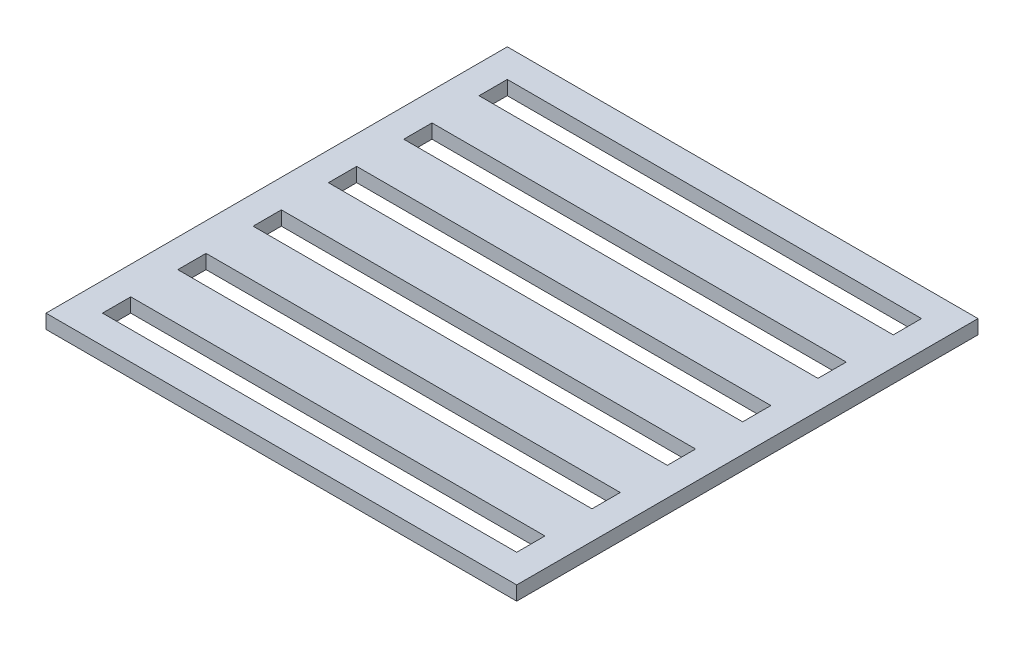
from build123d import *

# Parameters (mm, degrees)
CROQUIS3_W              = 490
CROQUIS3_H              = 15
SALIENTE_EXTRUIR1_DEPTH = 500
CROQUIS4_W              = 440
CROQUIS4_H              = 30
CORTAR_EXTRUIR1_DEPTH   = 15


with BuildPart() as part:
    # Croquis3 → Saliente-Extruir1 (new body)
    with BuildSketch(Plane(origin=(0, 0, 0), x_dir=(0, 0, -1), z_dir=(1, 0, 0))):
        Rectangle(CROQUIS3_W, CROQUIS3_H)
    extrude(amount=SALIENTE_EXTRUIR1_DEPTH)

    # Croquis4 → Cortar-Extruir1 (cut)
    with BuildSketch(Plane(origin=(0, 7.5, 0), x_dir=(1, 0, 0), z_dir=(0, 1, 0))):
        with Locations((250, 200)):
            Rectangle(CROQUIS4_W, CROQUIS4_H)
        with Locations((250, 120)):
            Rectangle(CROQUIS4_W, CROQUIS4_H)
        with Locations((250, 40)):
            Rectangle(CROQUIS4_W, CROQUIS4_H)
        with Locations((250, -40)):
            Rectangle(CROQUIS4_W, CROQUIS4_H)
        with Locations((250, -120)):
            Rectangle(CROQUIS4_W, CROQUIS4_H)
        with Locations((250, -200)):
            Rectangle(CROQUIS4_W, CROQUIS4_H)
    extrude(amount=-CORTAR_EXTRUIR1_DEPTH, mode=Mode.SUBTRACT)


solid = part.part
